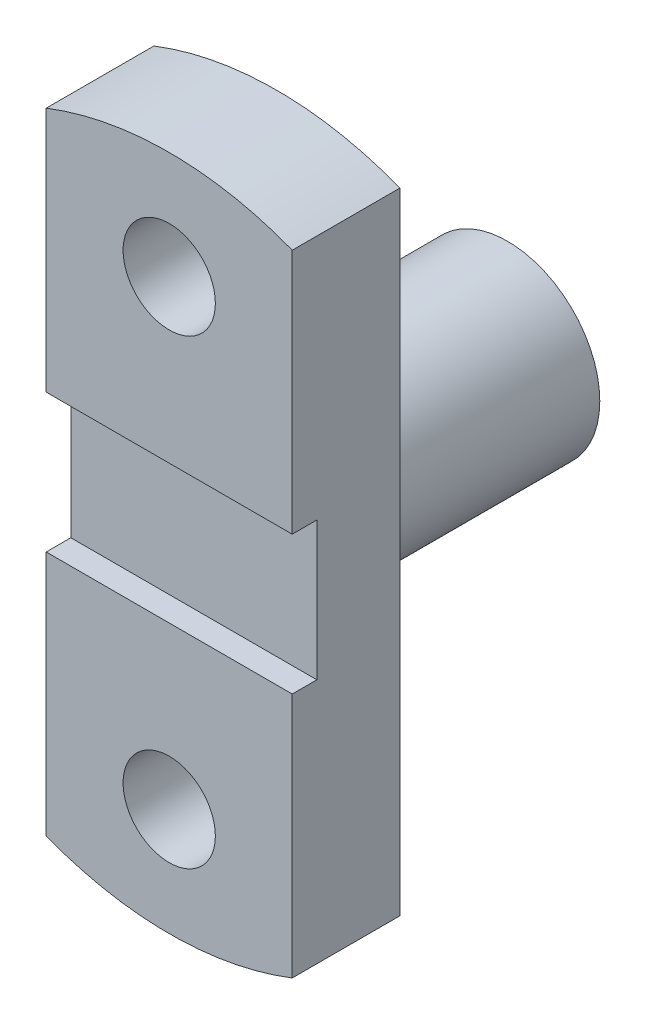
from build123d import *

# Parameters (mm, degrees)
SKETCH1_R           = 30
BOSS_EXTRUDE1_DEPTH = 75
SKETCH2_R           = 15
BOSS_EXTRUDE2_DEPTH = 35
CUT_EXTRUDE1_REACH  = 82
SKETCH3_W           = 8
SKETCH3_H           = 45


with BuildPart() as part:
    # Sketch1 → Boss-Extrude1 (new body)
    with BuildSketch(Plane.XY):
        Circle(SKETCH1_R)
    extrude(amount=BOSS_EXTRUDE1_DEPTH)

    # Sketch2 → Boss-Extrude2 (add)
    with BuildSketch(Plane.XY.offset(75)):
        with BuildLine():
            Line((-40, 102.46950766), (-40, -102.46950766))
            ThreePointArc((-40, -102.46950766), (0, -110), (40, -102.46950766))
            Line((40, -102.46950766), (40, 102.46950766))
            ThreePointArc((40, 102.46950766), (0, 110), (-40, 102.46950766))
        make_face()
        with Locations((0, -75)):
            Circle(SKETCH2_R, mode=Mode.SUBTRACT)
        with Locations((0, 75)):
            Circle(SKETCH2_R, mode=Mode.SUBTRACT)
    extrude(amount=BOSS_EXTRUDE2_DEPTH)

    # Sketch3 → Cut-Extrude1 (cut, up to next)
    with BuildSketch(Plane(origin=(40, 0, 0), x_dir=(0, 0, -1), z_dir=(1, 0, 0)), mode=Mode.PRIVATE) as cut_extrude1_sk1:
        with Locations((-106, 0)):
            Rectangle(SKETCH3_W, SKETCH3_H)
    cut_extrude1_tool1 = extrude(cut_extrude1_sk1.sketch, amount=-CUT_EXTRUDE1_REACH, mode=Mode.PRIVATE) & part.part
    add(cut_extrude1_tool1.solids().sort_by_distance((40, 0, 106))[0], mode=Mode.SUBTRACT)


solid = part.part
